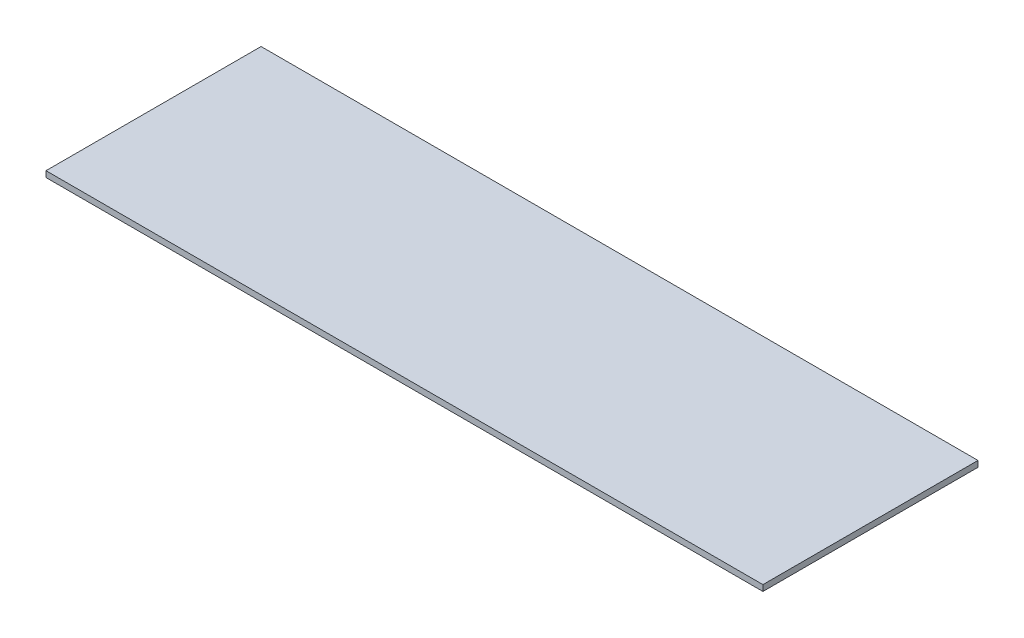
from build123d import *

# Parameters (mm, degrees)
SKETCH_1_W      = 1200
SKETCH_1_H      = 360
EXTRUDE_1_DEPTH = 10


with BuildPart() as part:
    # Эскиз1 → Бобышка-Вытянуть1 (new body)
    with BuildSketch(Plane(origin=(0, 0, 0), x_dir=(1, 0, 0), z_dir=(0, 1, 0))):
        Rectangle(SKETCH_1_W, SKETCH_1_H)
    extrude(amount=EXTRUDE_1_DEPTH)


solid = part.part
